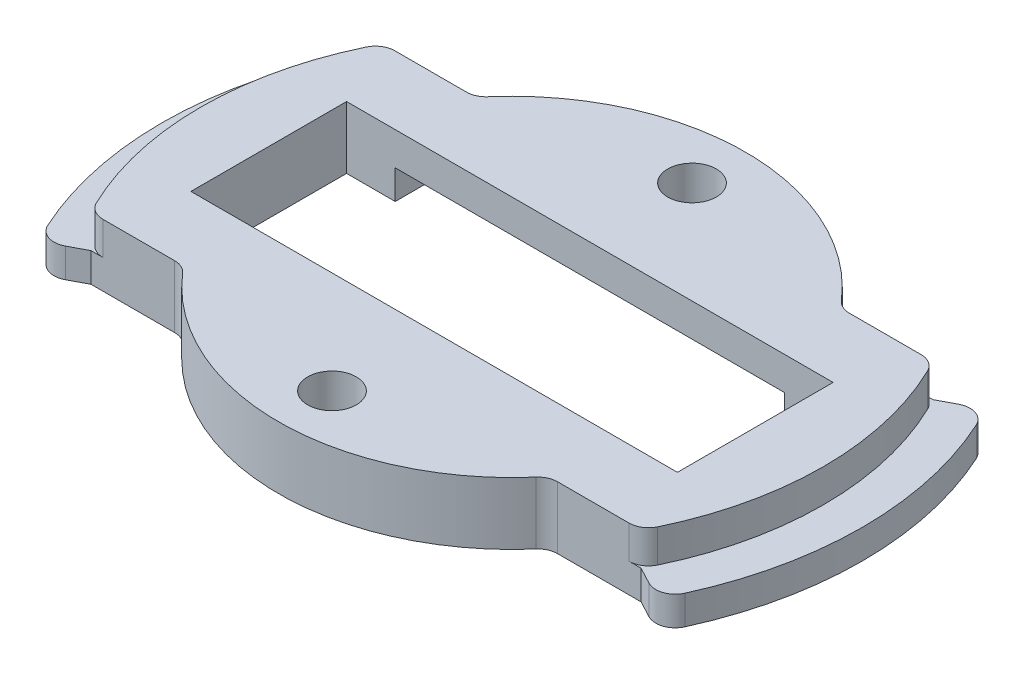
from build123d import *

# Parameters (mm, degrees)
SKETCH1_W           = 40
SKETCH1_H           = 16
BOSS_EXTRUDE1_DEPTH = 6.4
SKETCH2_W           = 40
SKETCH2_H           = 4
CUT_EXTRUDE1_DEPTH  = 3
SKETCH3_W           = 5
SKETCH3_H           = 16
CUT_EXTRUDE2_DEPTH  = 7.4
BOSS_EXTRUDE2_DEPTH = 6.4
BOSS_EXTRUDE3_DEPTH = 3
FILLET1_R           = 2
SKETCH7_R           = 2.5
CUT_EXTRUDE3_DEPTH  = 7.4


with BuildPart() as part:
    # Sketch1 → Boss-Extrude1 (new body)
    with BuildSketch(Plane(origin=(0, 0, 0), x_dir=(1, 0, 0), z_dir=(0, 1, 0))):
        with BuildLine():
            Line((28.26658805, 15), (-28.26658805, 15))
            ThreePointArc((-28.26658805, 15), (-32, 0), (-28.26658805, -15))
            Line((-28.26658805, -15), (28.26658805, -15))
            ThreePointArc((28.26658805, -15), (32, 0), (28.26658805, 15))
        make_face()
        Rectangle(SKETCH1_W, SKETCH1_H, mode=Mode.SUBTRACT)
    extrude(amount=BOSS_EXTRUDE1_DEPTH)

    # Sketch2 → Cut-Extrude1 (cut)
    with BuildSketch(Plane.XZ):
        with Locations((0, 10)):
            Rectangle(SKETCH2_W, SKETCH2_H)
        with Locations((0, -10)):
            Rectangle(SKETCH2_W, SKETCH2_H)
    extrude(amount=-CUT_EXTRUDE1_DEPTH, mode=Mode.SUBTRACT)

    # Sketch3 → Cut-Extrude2 (cut, through all)
    with BuildSketch(Plane.XZ):
        with Locations((-22.5, 0)):
            Rectangle(SKETCH3_W, SKETCH3_H)
        with Locations((22.5, 0)):
            Rectangle(SKETCH3_W, SKETCH3_H)
    extrude(amount=-CUT_EXTRUDE2_DEPTH, mode=Mode.SUBTRACT)

    # Sketch5 → Boss-Extrude2 (add)
    with BuildSketch(Plane(origin=(0, 6.4, 0), x_dir=(1, 0, 0), z_dir=(0, 1, 0))):
        with BuildLine():
            Line((-18.734993995, -15), (18.734993995, -15))
            ThreePointArc((18.734993995, -15), (0, -24), (-18.734993995, -15))
        make_face()
        with BuildLine():
            Line((-18.734993995, 15), (18.734993995, 15))
            ThreePointArc((18.734993995, 15), (0, 24), (-18.734993995, 15))
        make_face()
    extrude(amount=-BOSS_EXTRUDE2_DEPTH)

    # Sketch6 → Boss-Extrude3 (add)
    with BuildSketch(Plane.XZ):
        with BuildLine():
            Line((-31.799911556, 16.875), (-28.26658805, 15))
            ThreePointArc((-28.26658805, 15), (-32, 0), (-28.26658805, -15))
            Line((-28.26658805, -15), (-31.799911556, -16.875))
            ThreePointArc((-31.799911556, -16.875), (-36, 0), (-31.799911556, 16.875))
        make_face()
        with BuildLine():
            ThreePointArc((31.799911556, 16.875), (36, 0), (31.799911556, -16.875))
            Line((31.799911556, -16.875), (28.26658805, -15))
            ThreePointArc((28.26658805, -15), (32, 0), (28.26658805, 15))
            Line((28.26658805, 15), (31.799911556, 16.875))
        make_face()
    extrude(amount=-BOSS_EXTRUDE3_DEPTH)

    # Fillet1
    fillet1_edges = [part.edges().sort_by_distance(p)[0] for p in [
        (-31.799911556, 1.5, 16.875),
        (-31.799911556, 1.5, -16.875),
        (31.799911556, 1.5, 16.875),
        (31.799911556, 1.5, -16.875),
        (28.26658805, 4.7, 15),
        (-28.26658805, 4.7, 15),
        (-28.26658805, 4.7, -15),
        (28.26658805, 4.7, -15),
        (-18.734993995, 3.2, 15),
        (18.734993995, 3.2, 15),
        (18.734993995, 3.2, -15),
        (-18.734993995, 3.2, -15),
    ]]
    fillet(fillet1_edges, radius=FILLET1_R)

    # Sketch7 → Cut-Extrude3 (cut, through all)
    with BuildSketch(Plane(origin=(0, 6.4, 0), x_dir=(1, 0, 0), z_dir=(0, 1, 0))):
        with Locations((0, 18.5)):
            Circle(SKETCH7_R)
        with Locations((0, -18.5)):
            Circle(SKETCH7_R)
    extrude(amount=-CUT_EXTRUDE3_DEPTH, mode=Mode.SUBTRACT)


solid = part.part
